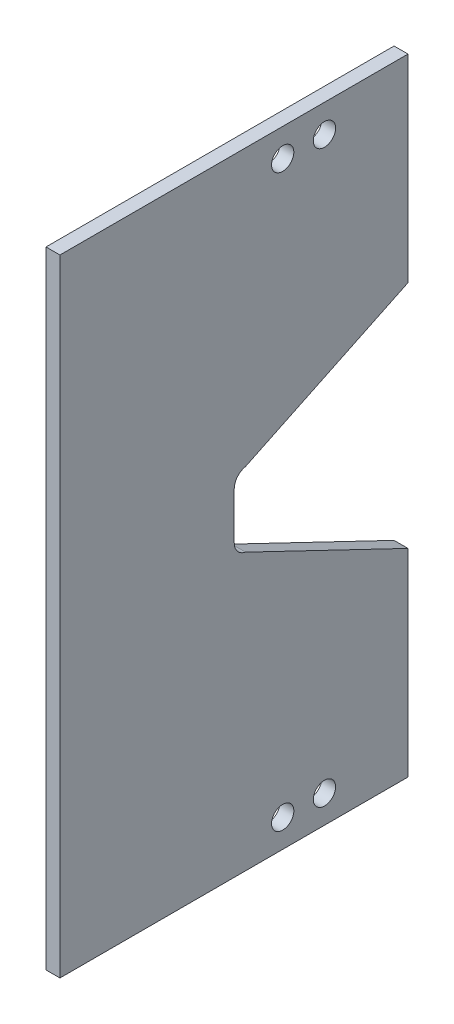
from build123d import *

# Parameters (mm, degrees)
EXTRUDE_1_DEPTH     = 2
FILLET_1_R          = 2
FILLET_2_R          = 2
FILLET_3_R          = 2
FILLET_4_R          = 2
SKETCH_2_W          = 12
SKETCH_2_H          = 89.95
EXTRUDE_2_DEPTH     = 2
CUT_EXTRUDE_1_DEPTH = 10
SKETCH_6_R          = 1.6
CUT_EXTRUDE_2_DEPTH = 10
SKETCH_7_W          = 10
SKETCH_7_H          = 89.95
EXTRUDE_3_DEPTH     = 2


with BuildPart() as part:
    # 草图1 → 凸台-拉伸1 (new body)
    with BuildSketch(Plane(origin=(-0.79375, 0, 0), x_dir=(0, -1, 0), z_dir=(-1, 0, 0))):
        with BuildLine():
            Line((38.795, 5), (12.795, 5))
            ThreePointArc((12.795, 5), (11.380786438, 4.414213562), (10.795, 3))
            Line((10.795, 3), (10.795, -13))
            ThreePointArc((10.795, -13), (11.380786438, -14.414213562), (12.795, -15))
            Line((12.795, -15), (47.795, -15))
            Line((47.795, -15), (50.77, -0.039144756))
            Line((50.77, -0.039144756), (55.77, -0.039144756))
            Line((55.77, -0.039144756), (60.77, -0.039144756))
            Line((60.77, -0.039144756), (63.745, -15))
            Line((63.745, -15), (98.745, -15))
            ThreePointArc((98.745, -15), (100.159213562, -14.414213562), (100.745, -13))
            Line((100.745, -13), (100.745, 3))
            ThreePointArc((100.745, 3), (100.159213562, 4.414213562), (98.745, 5))
            Line((98.745, 5), (72.745, 5))
            Line((72.745, 5), (38.795, 5))
        make_face()
    extrude(amount=-EXTRUDE_1_DEPTH)

    # 圆角1
    fillet_1_edges = [part.edges().sort_by_distance(p)[0] for p in [
        (0.20625, -47.795, -15),
    ]]
    fillet(fillet_1_edges, radius=FILLET_1_R)

    # 圆角2
    fillet_2_edges = [part.edges().sort_by_distance(p)[0] for p in [
        (0.20625, -50.77, -0.039144756),
    ]]
    fillet(fillet_2_edges, radius=FILLET_2_R)

    # 圆角3
    fillet_3_edges = [part.edges().sort_by_distance(p)[0] for p in [
        (0.20625, -60.77, -0.039144756),
    ]]
    fillet(fillet_3_edges, radius=FILLET_3_R)

    # 圆角4
    fillet_4_edges = [part.edges().sort_by_distance(p)[0] for p in [
        (0.20625, -63.745, -15),
    ]]
    fillet(fillet_4_edges, radius=FILLET_4_R)

    # 草图2 → 凸台-拉伸2 (add)
    with BuildSketch(Plane(origin=(1.20625, 0, 0), x_dir=(0, 0, -1), z_dir=(1, 0, 0))):
        with Locations((-9, -55.77)):
            Rectangle(SKETCH_2_W, SKETCH_2_H)
        Polygon((13.39006724, -48.115138781), (25, -45.806477318), (25, -10.795), (13, -10.795), align=None)
        Polygon((13.39006724, -63.424861219), (25, -65.733522682), (25, -100.745), (13, -100.745), align=None)
    extrude(amount=-EXTRUDE_2_DEPTH)

    # 草图5 → 切除-拉伸1 (cut)
    with BuildSketch(Plane(origin=(1.20625, 0, 0), x_dir=(0, 0, -1), z_dir=(1, 0, 0))):
        Polygon((1.649077515, -50.449861219), (25, -45.806477318), (25, -39.241825321), align=None)
        Polygon((1.649077515, -61.090138781), (25, -72.298174679), (25, -65.733522682), align=None)
    extrude(amount=-CUT_EXTRUDE_1_DEPTH, mode=Mode.SUBTRACT)

    # 草图6 → 切除-拉伸2 (cut)
    with BuildSketch(Plane(origin=(1.20625, 0, 0), x_dir=(0, 0, -1), z_dir=(1, 0, 0))):
        with Locations((13, -14.795)):
            Circle(SKETCH_6_R)
        with Locations((7, -14.795)):
            Circle(SKETCH_6_R)
        with Locations((13, -96.745)):
            Circle(SKETCH_6_R)
        with Locations((7, -96.745)):
            Circle(SKETCH_6_R)
    extrude(amount=-CUT_EXTRUDE_2_DEPTH, mode=Mode.SUBTRACT)

    # 草图7 → 凸台-拉伸3 (add)
    with BuildSketch(Plane.ZY.offset(0.79375)):
        with Locations((20, -55.77)):
            Rectangle(SKETCH_7_W, SKETCH_7_H)
    extrude(amount=-EXTRUDE_3_DEPTH)


solid = part.part
